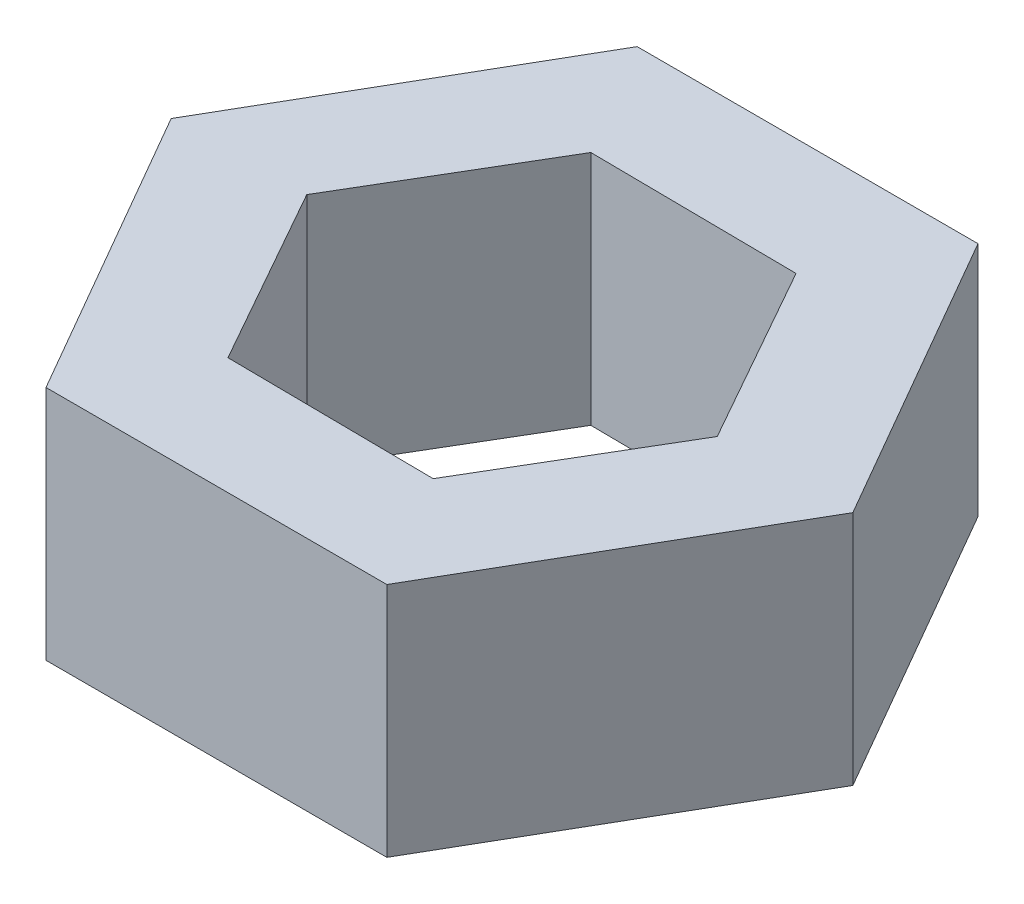
from build123d import *

# Parameters (mm, degrees)
BOSS_EXTRUDE1_DEPTH = 5


with BuildPart() as part:
    # Sketch1 → Boss-Extrude1 (new body)
    with BuildSketch(Plane(origin=(0, 0, 0), x_dir=(1, 0, 0), z_dir=(0, 1, 0))):
        Polygon((3.604313322, -6.252380252), (7.216876793, -0.004763226), (3.612563471, 6.247617026), (-3.604313322, 6.252380252), (-7.216876793, 0.004763226), (-3.612563471, -6.247617026), align=None)
        Polygon((2.154497585, -3.822495715), (4.387627187, -0.045398217), (2.233129603, 3.777097498), (-2.154497585, 3.822495715), (-4.387627187, 0.045398217), (-2.233129603, -3.777097498), align=None, mode=Mode.SUBTRACT)
    extrude(amount=BOSS_EXTRUDE1_DEPTH)


solid = part.part
